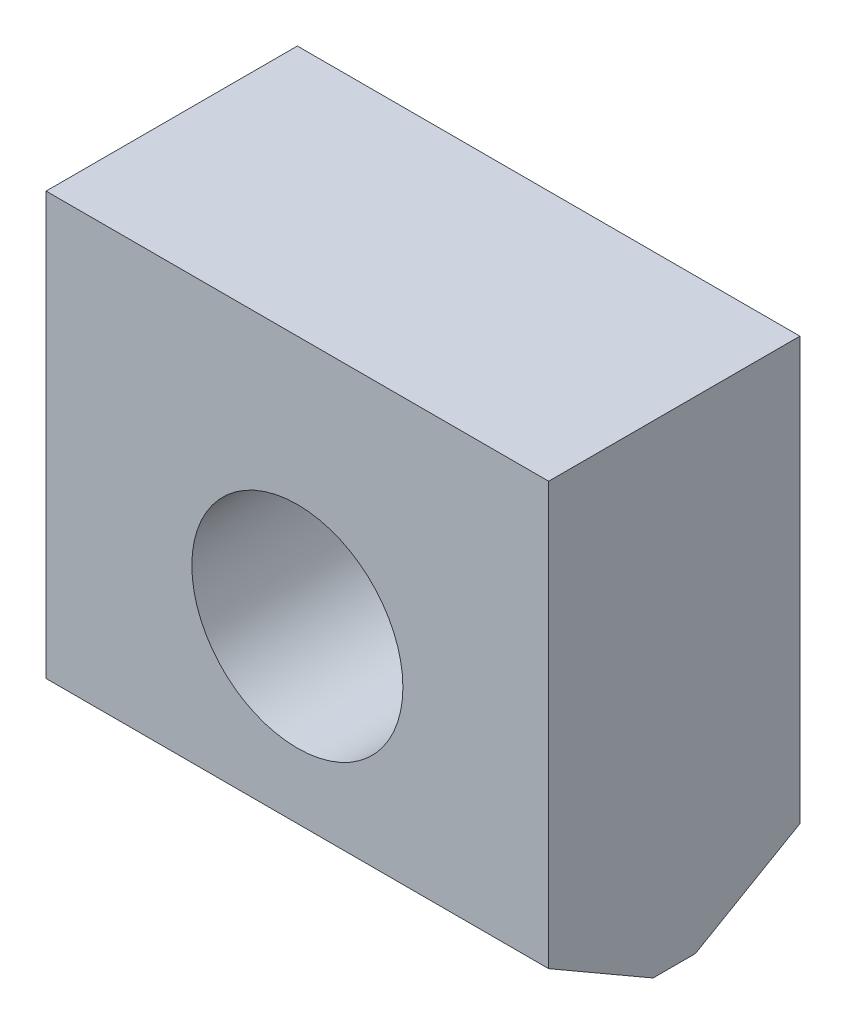
from build123d import *

# Parameters (mm, degrees)
SKETCH_1_W          = 50
SKETCH_1_H          = 48
EXTRUDE_1_DEPTH     = 25
SKETCH_2_R          = 10.5
CUT_EXTRUDE_1_DEPTH = 26
CHAMFER_1_SIZE      = 6
CHAMFER_1_SIZE2     = 10.392304845
CHAMFER_2_SIZE      = 6
CHAMFER_2_SIZE2     = 10.392304845


with BuildPart() as part:
    # Эскиз1 → Бобышка-Вытянуть1 (new body)
    with BuildSketch(Plane.XY):
        with Locations((25, 24)):
            Rectangle(SKETCH_1_W, SKETCH_1_H)
    extrude(amount=EXTRUDE_1_DEPTH)

    # Эскиз2 → Вырез-Вытянуть1 (cut, through all)
    with BuildSketch(Plane.XY.offset(25)):
        with Locations((25, 23)):
            Circle(SKETCH_2_R)
    extrude(amount=-CUT_EXTRUDE_1_DEPTH, mode=Mode.SUBTRACT)

    # Фаска1
    chamfer_1_edges = [part.edges().sort_by_distance(p)[0] for p in [
        (25, 0, 0),
    ]]
    chamfer_1_side = [part.faces().sort_by_distance(p)[0] for p in [
        (25, 0.693108938, 0),
    ]]
    chamfer(chamfer_1_edges, length=CHAMFER_1_SIZE, length2=CHAMFER_1_SIZE2, reference=chamfer_1_side[0])

    # Фаска2
    chamfer_2_edges = [part.edges().sort_by_distance(p)[0] for p in [
        (25, 0, 25),
    ]]
    chamfer_2_side = [part.faces().sort_by_distance(p)[0] for p in [
        (25, 0.693108938, 25),
    ]]
    chamfer(chamfer_2_edges, length=CHAMFER_2_SIZE, length2=CHAMFER_2_SIZE2, reference=chamfer_2_side[0])


solid = part.part
